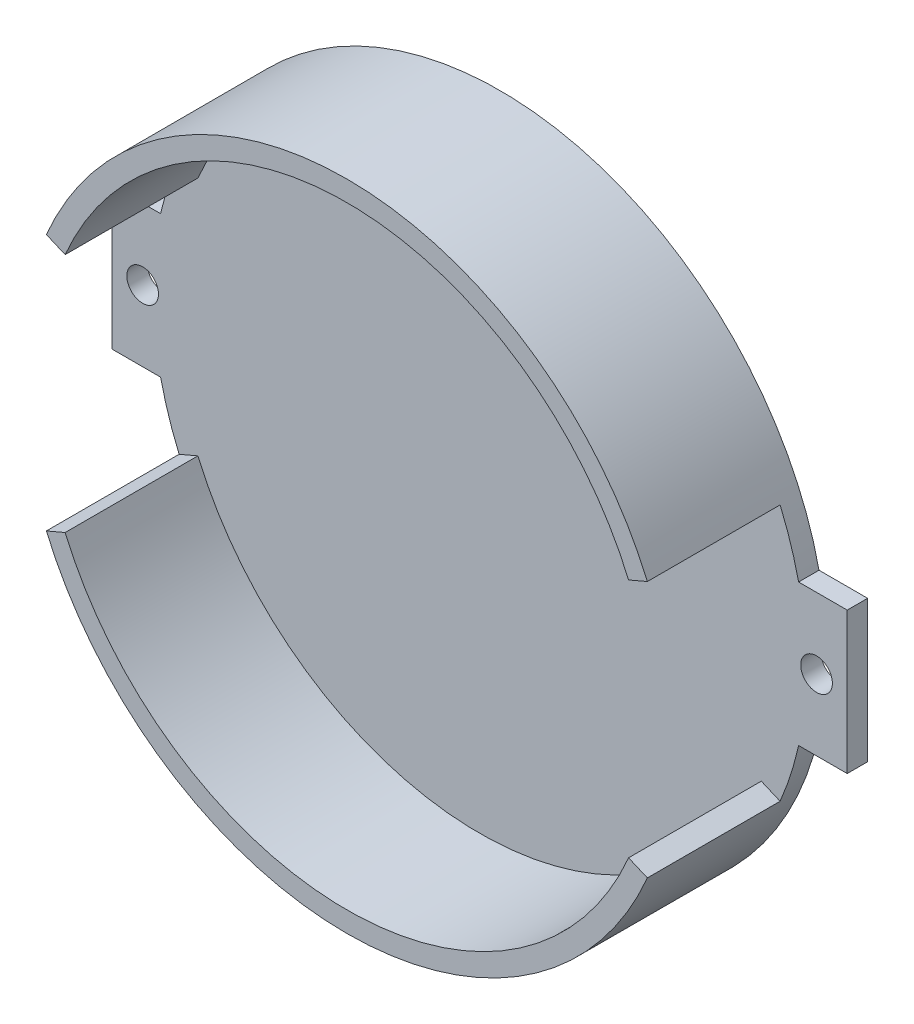
from build123d import *

# Parameters (mm, degrees)
BOSS_EXTRUDE1_DEPTH = 2
BOSS_EXTRUDE2_DEPTH = 13
SKETCH3_R           = 1.55
CUT_EXTRUDE1_DEPTH  = 16


with BuildPart() as part:
    # Sketch1 → Boss-Extrude1 (new body)
    with BuildSketch(Plane.XY):
        with BuildLine():
            Line((-31.239860577, -6.933333333), (-36, -6.933333333))
            Line((-36, -6.933333333), (-36, 6.933333333))
            Line((-36, 6.933333333), (-31.239860577, 6.933333333))
            ThreePointArc((-31.239860577, 6.933333333), (0, 32), (31.239860577, 6.933333333))
            Line((31.239860577, 6.933333333), (36, 6.933333333))
            Line((36, 6.933333333), (36, -6.933333333))
            Line((36, -6.933333333), (31.239860577, -6.933333333))
            ThreePointArc((31.239860577, -6.933333333), (0, -32), (-31.239860577, -6.933333333))
        make_face()
    extrude(amount=BOSS_EXTRUDE1_DEPTH)

    # Sketch2 → Boss-Extrude2 (add)
    with BuildSketch(Plane.XY.offset(2)):
        with BuildLine():
            Line((-29.428567245, 12.568191195), (-27.589281792, 11.782679245))
            ThreePointArc((-27.589281792, 11.782679245), (0, 30), (27.589281792, 11.782679245))
            Line((27.589281792, 11.782679245), (29.428567245, 12.568191195))
            ThreePointArc((29.428567245, 12.568191195), (0, 32), (-29.428567245, 12.568191195))
        make_face()
        with BuildLine():
            Line((27.589281792, -11.782679245), (29.428567245, -12.568191195))
            ThreePointArc((29.428567245, -12.568191195), (0, -32), (-29.428567245, -12.568191195))
            Line((-29.428567245, -12.568191195), (-27.589281792, -11.782679245))
            ThreePointArc((-27.589281792, -11.782679245), (0, -30), (27.589281792, -11.782679245))
        make_face()
    extrude(amount=BOSS_EXTRUDE2_DEPTH)

    # Sketch3 → Cut-Extrude1 (cut, through all)
    with BuildSketch(Plane(origin=(0, 0, 0), x_dir=(-1, 0, 0), z_dir=(0, 0, -1))):
        with Locations((-33, 0)):
            Circle(SKETCH3_R)
        with Locations((33, 0)):
            Circle(SKETCH3_R)
    extrude(amount=-CUT_EXTRUDE1_DEPTH, mode=Mode.SUBTRACT)


solid = part.part
